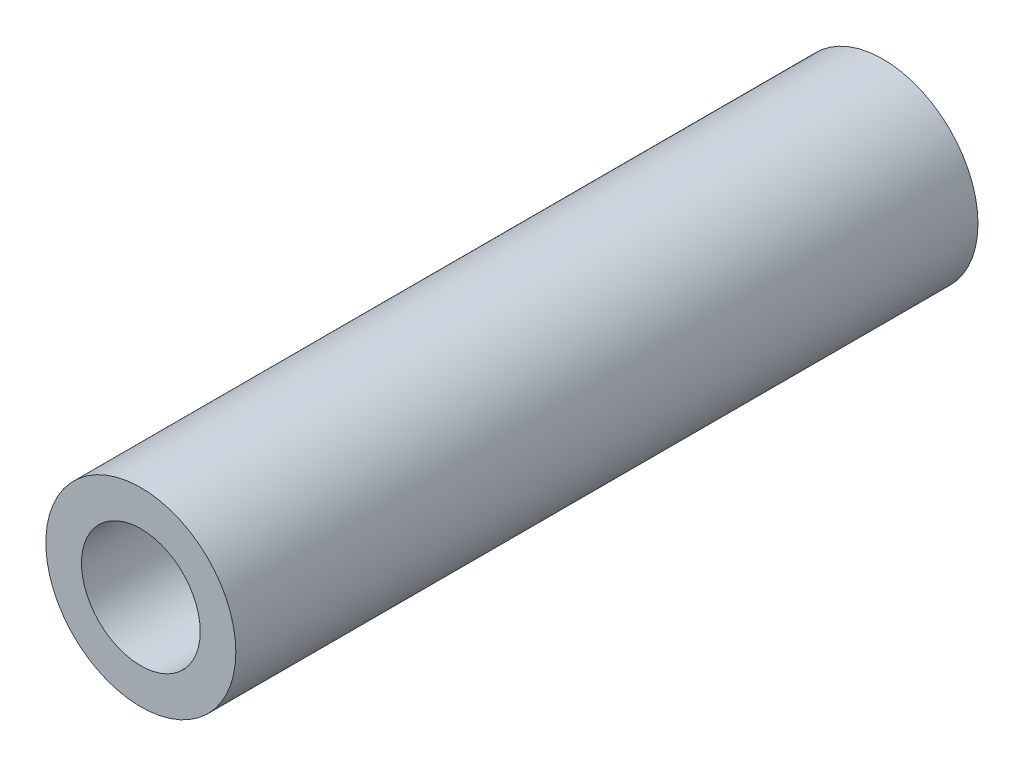
from build123d import *

# Parameters (mm, degrees)
SKETCH2_R           = 3.2
BOSS_EXTRUDE1_DEPTH = 25
SKETCH3_R           = 2
CUT_EXTRUDE1_DEPTH  = 25


with BuildPart() as part:
    # Sketch2 → Boss-Extrude1 (new body)
    with BuildSketch(Plane.XY):
        Circle(SKETCH2_R)
    extrude(amount=BOSS_EXTRUDE1_DEPTH)

    # Sketch3 → Cut-Extrude1 (cut)
    with BuildSketch(Plane.XY.offset(25)):
        Circle(SKETCH3_R)
    extrude(amount=-CUT_EXTRUDE1_DEPTH, mode=Mode.SUBTRACT)


solid = part.part
